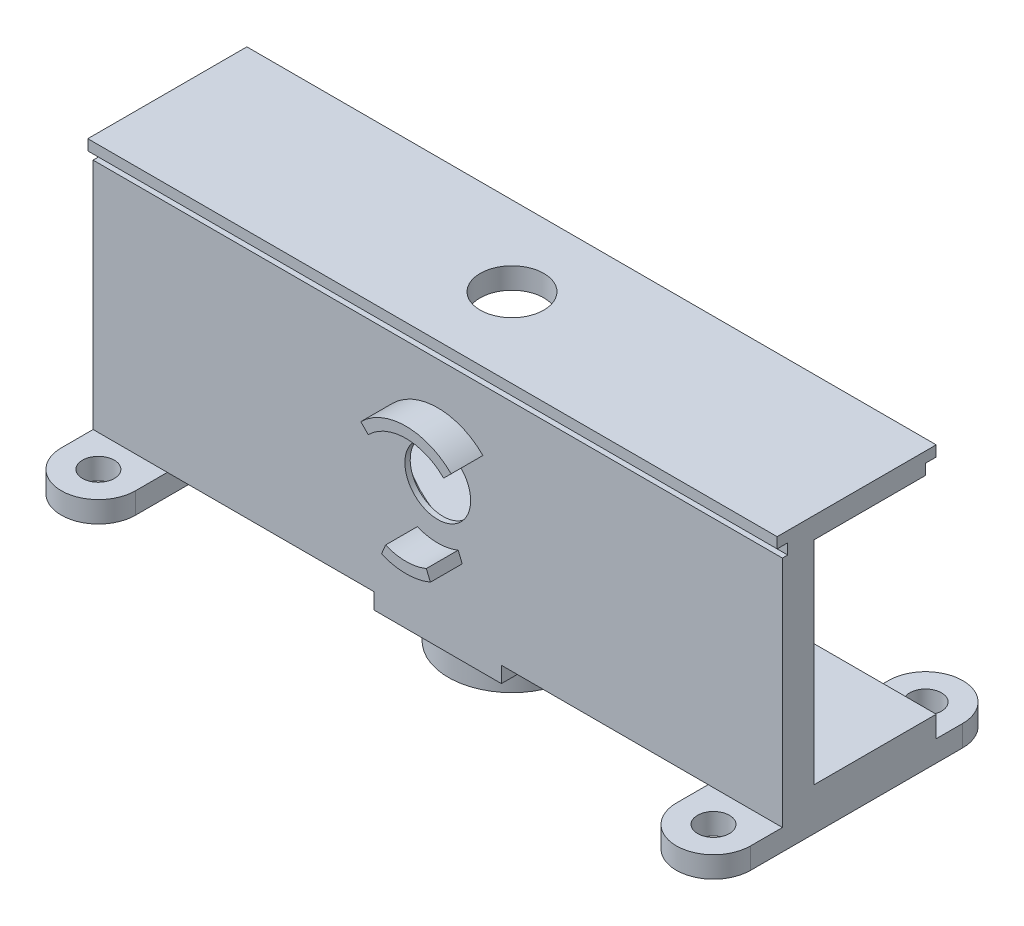
from build123d import *

# Parameters (mm, degrees)
SALIENTE_EXTRUIR1_DEPTH      = 32.5
SALIENTE_EXTRUIR1_DEPTH_BACK = 32.5
CROQUIS1_W                   = 15
CROQUIS1_H                   = 24
CORTAR_EXTRUIR1_DEPTH        = 65.5
CORTAR_EXTRUIR2_DEPTH        = 65.5
SALIENTE_EXTRUIR2_DEPTH      = 3
CROQUIS5_R                   = 3.1
CORTAR_EXTRUIR3_DEPTH        = 3
CROQUIS6_R                   = 6.5
CORTAR_EXTRUIR5_DEPTH        = 2.5
CROQUIS7_W                   = 12
CROQUIS7_H                   = 14.5
SALIENTE_EXTRUIR3_DEPTH      = 1.5
CROQUIS8_R                   = 6
CROQUIS8_R_2                 = 3.5
SALIENTE_EXTRUIR4_DEPTH      = 3
CORTAR_EXTRUIR6_DEPTH        = 2
CROQUIS10_R                  = 1.5
CORTAR_EXTRUIR7_DEPTH        = 2
CROQUIS11_R                  = 3
CORTAR_EXTRUIR8_DEPTH        = 2
CROQUIS12_R                  = 1.5
SALIENTE_EXTRUIR5_DEPTH      = 2


with BuildPart() as part:
    # Croquis1 → Saliente-Extruir1 (new, two sides: drawn at the far end of the back side and taken through both)
    with BuildSketch(Plane(origin=(0, 0, 0), x_dir=(0, 0, -1), z_dir=(1, 0, 0)).offset(-SALIENTE_EXTRUIR1_DEPTH_BACK)):
        Rectangle(CROQUIS1_W, CROQUIS1_H)
    extrude(amount=SALIENTE_EXTRUIR1_DEPTH + SALIENTE_EXTRUIR1_DEPTH_BACK)

    # Croquis2 → Cortar-Extruir1 (cut)
    with BuildSketch(Plane(origin=(32.5, 0, 0), x_dir=(0, 0, -1), z_dir=(1, 0, 0))):
        Polygon((-7.5, 11), (-6.5, 11), (-6.5, 10), (-7, 10), (-7, -12), (-7.5, -12), align=None)
    extrude(amount=-CORTAR_EXTRUIR1_DEPTH, mode=Mode.SUBTRACT)

    # Croquis3 → Cortar-Extruir2 (cut)
    with BuildSketch(Plane(origin=(32.5, 0, 0), x_dir=(0, 0, -1), z_dir=(1, 0, 0))):
        Polygon((7.5, 11), (6.5, 11), (6.5, 10), (-4, 10), (-4, -10), (7.5, -10), align=None)
    extrude(amount=-CORTAR_EXTRUIR2_DEPTH, mode=Mode.SUBTRACT)

    # Croquis4 → Saliente-Extruir2 (add)
    with BuildSketch(Plane.XY.offset(7)):
        with BuildLine():
            Line((-3.553211575, 3.553211575), (-4.260318357, 4.260318357))
            ThreePointArc((-4.260318357, 4.260318357), (0, 6.025), (4.260318357, 4.260318357))
            Line((4.260318357, 4.260318357), (3.553211575, 3.553211575))
            ThreePointArc((3.553211575, 3.553211575), (0, 5.025), (-3.553211575, 3.553211575))
        make_face()
        with BuildLine():
            Line((-1.922984248, -4.642494651), (-2.30566768, -5.566374183))
            ThreePointArc((-2.30566768, -5.566374183), (0, -6.025), (2.30566768, -5.566374183))
            Line((2.30566768, -5.566374183), (1.922984248, -4.642494651))
            ThreePointArc((1.922984248, -4.642494651), (0, -5.025), (-1.922984248, -4.642494651))
        make_face()
    extrude(amount=SALIENTE_EXTRUIR2_DEPTH)

    # Croquis5 → Cortar-Extruir3 (cut)
    with BuildSketch(Plane.XY.offset(7)):
        Circle(CROQUIS5_R)
    extrude(amount=-CORTAR_EXTRUIR3_DEPTH, mode=Mode.SUBTRACT)

    # Croquis6 → Cortar-Extruir5 (cut)
    with BuildSketch(Plane(origin=(0, 0, 4), x_dir=(-1, 0, 0), z_dir=(0, 0, -1))):
        Circle(CROQUIS6_R)
    extrude(amount=-CORTAR_EXTRUIR5_DEPTH, mode=Mode.SUBTRACT)

    # Croquis7 → Saliente-Extruir3 (add)
    with BuildSketch(Plane.XZ.offset(12)):
        with Locations((0, -0.25)):
            Rectangle(CROQUIS7_W, CROQUIS7_H)
    extrude(amount=SALIENTE_EXTRUIR3_DEPTH)

    # Croquis8 → Saliente-Extruir4 (add)
    with BuildSketch(Plane.XZ.offset(13.5)):
        Circle(CROQUIS8_R)
        Circle(CROQUIS8_R_2, mode=Mode.SUBTRACT)
    extrude(amount=SALIENTE_EXTRUIR4_DEPTH)

    # Croquis9 → Cortar-Extruir6 (cut)
    with BuildSketch(Plane(origin=(0, -10, 0), x_dir=(1, 0, 0), z_dir=(0, 1, 0))):
        with BuildLine():
            Line((3, 7.5), (-3, 7.5))
            Line((-3, 7.5), (-3, 0.5))
            ThreePointArc((-3, 0.5), (0, -2.5), (3, 0.5))
            Line((3, 0.5), (3, 7.5))
        make_face()
    extrude(amount=-CORTAR_EXTRUIR6_DEPTH, mode=Mode.SUBTRACT)

    # Croquis10 → Cortar-Extruir7 (cut)
    with BuildSketch(Plane.XZ.offset(13.5)):
        Circle(CROQUIS10_R)
    extrude(amount=-CORTAR_EXTRUIR7_DEPTH, mode=Mode.SUBTRACT)

    # Croquis11 → Cortar-Extruir8 (cut)
    with BuildSketch(Plane(origin=(0, 12, 0), x_dir=(1, 0, 0), z_dir=(0, 1, 0))):
        Circle(CROQUIS11_R)
    extrude(amount=-CORTAR_EXTRUIR8_DEPTH, mode=Mode.SUBTRACT)

    # Croquis12 → Saliente-Extruir5 (add)
    # profile 1 of 2: a face of its own
    with BuildSketch(Plane.XZ.offset(12)):
        with BuildLine():
            Line((32.5, -10), (32.5, 10))
            ThreePointArc((32.5, 10), (29, 13.5), (25.5, 10))
            Line((25.5, 10), (25.5, -10))
            ThreePointArc((25.5, -10), (29, -13.5), (32.5, -10))
        make_face()
        with Locations((29, 10)):
            Circle(CROQUIS12_R, mode=Mode.SUBTRACT)
        with Locations((29, -10)):
            Circle(CROQUIS12_R, mode=Mode.SUBTRACT)
    # profile 2 of 2: a face of its own
    with BuildSketch(Plane.XZ.offset(12)):
        with BuildLine():
            Line((-25.5, -10), (-25.5, 10))
            ThreePointArc((-25.5, 10), (-29, 13.5), (-32.5, 10))
            Line((-32.5, 10), (-32.5, -10))
            ThreePointArc((-32.5, -10), (-29, -13.5), (-25.5, -10))
        make_face()
        with Locations((-29, 10)):
            Circle(CROQUIS12_R, mode=Mode.SUBTRACT)
        with Locations((-29, -10)):
            Circle(CROQUIS12_R, mode=Mode.SUBTRACT)
    extrude(amount=SALIENTE_EXTRUIR5_DEPTH)


solid = part.part
